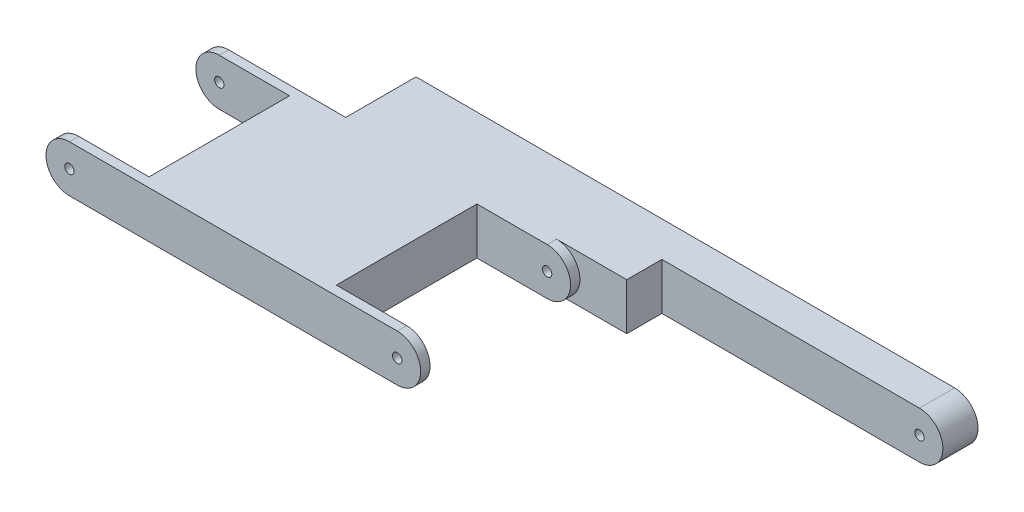
from build123d import *

# Parameters (mm, degrees)
EXTRUDE_1_DEPTH          = 34
SKETCH_2_R               = 1
CUT_EXTRUDE_4_DEPTH      = 35
CUT_EXTRUDE_4_DEPTH_BACK = 30
SKETCH_3_W               = 20
SKETCH_3_H               = 30
CUT_EXTRUDE_5_DEPTH      = 30
CUT_EXTRUDE_5_DEPTH_BACK = 30
EXTRUDE_4_DEPTH          = 15
SKETCH_5_R               = 1
CUT_EXTRUDE_7_DEPTH      = 16
SKETCH_6_W               = 15
SKETCH_6_H               = 10
EXTRUDE_5_DEPTH          = 10
SKETCH_7_W               = 70
SKETCH_7_H               = 10
CUT_EXTRUDE_8_DEPTH      = 10
CUT_EXTRUDE_8_DEPTH_BACK = 10


with BuildPart() as part:
    # 草圖1 → 填料-伸長1 (new body)
    with BuildSketch(Plane.XY):
        with BuildLine():
            Line((-35, 5), (35, 5))
            ThreePointArc((35, 5), (40, 0), (35, -5))
            Line((35, -5), (-35, -5))
            ThreePointArc((-35, -5), (-40, 0), (-35, 5))
        make_face()
    extrude(amount=EXTRUDE_1_DEPTH)

    # 草圖2 → 除料-伸長4 (cut, two sides)
    with BuildSketch(Plane.XY) as cut_extrude_4_sk:
        with Locations((-35, 0)):
            Circle(SKETCH_2_R)
        with Locations((35, 0)):
            Circle(SKETCH_2_R)
    extrude(amount=CUT_EXTRUDE_4_DEPTH, mode=Mode.SUBTRACT)
    extrude(cut_extrude_4_sk.sketch, amount=-CUT_EXTRUDE_4_DEPTH_BACK, mode=Mode.SUBTRACT)

    # 草圖3 → 除料-伸長5 (cut, two sides)
    with BuildSketch(Plane(origin=(0, 0, 0), x_dir=(1, 0, 0), z_dir=(0, 1, 0))) as cut_extrude_5_sk:
        with Locations((-30, -17)):
            Rectangle(SKETCH_3_W, SKETCH_3_H)
        with Locations((30, -17)):
            Rectangle(SKETCH_3_W, SKETCH_3_H)
    extrude(amount=CUT_EXTRUDE_5_DEPTH, mode=Mode.SUBTRACT)
    extrude(cut_extrude_5_sk.sketch, amount=-CUT_EXTRUDE_5_DEPTH_BACK, mode=Mode.SUBTRACT)

    # 草圖4 → 填料-伸長4 (add)
    with BuildSketch(Plane.XY):
        with BuildLine():
            Line((0, 5), (105, 5))
            ThreePointArc((105, 5), (110, 0), (105, -5))
            Line((105, -5), (0, -5))
            Line((0, -5), (0, 5))
        make_face()
    extrude(amount=-EXTRUDE_4_DEPTH)

    # 草圖5 → 除料-伸長7 (cut, through all)
    with BuildSketch(Plane.XY):
        with Locations((35, 0)):
            Circle(SKETCH_5_R)
        with Locations((105, 0)):
            Circle(SKETCH_5_R)
    extrude(amount=-CUT_EXTRUDE_7_DEPTH, mode=Mode.SUBTRACT)

    # 草圖6 → 填料-伸長5 (add)
    with BuildSketch(Plane(origin=(0, 0, 0), x_dir=(0, 0, -1), z_dir=(1, 0, 0))):
        with Locations((7.5, 0)):
            Rectangle(SKETCH_6_W, SKETCH_6_H)
    extrude(amount=-EXTRUDE_5_DEPTH)

    # 草圖7 → 除料-伸長8 (cut, two sides)
    with BuildSketch(Plane(origin=(0, 0, 0), x_dir=(1, 0, 0), z_dir=(0, 1, 0))) as cut_extrude_8_sk:
        with Locations((85, 2.5)):
            Rectangle(SKETCH_7_W, SKETCH_7_H)
    extrude(amount=CUT_EXTRUDE_8_DEPTH, mode=Mode.SUBTRACT)
    extrude(cut_extrude_8_sk.sketch, amount=-CUT_EXTRUDE_8_DEPTH_BACK, mode=Mode.SUBTRACT)


solid = part.part
